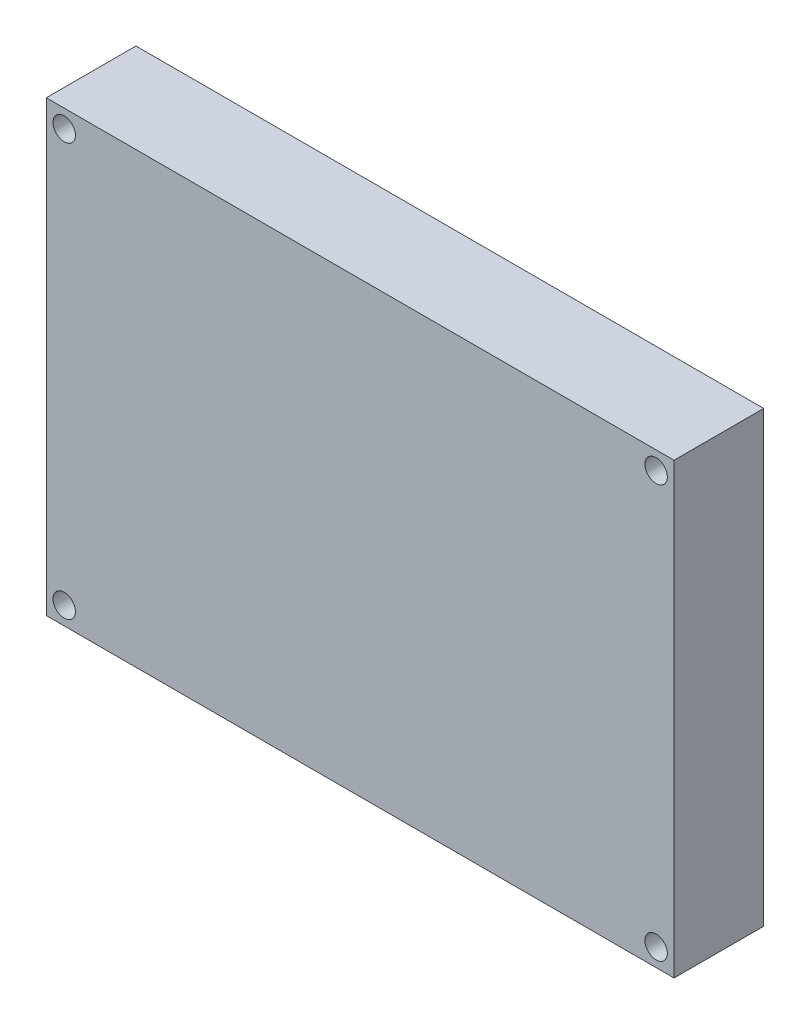
from build123d import *

# Parameters (mm, degrees)
SCHIZZO1_W                   = 70
SCHIZZO1_H                   = 50
ESTRUSIONE_ESTRUSIONE1_DEPTH = 10
SCHIZZO2_R                   = 1.25
TAGLIO_ESTRUSIONE1_DEPTH     = 11


with BuildPart() as part:
    # Schizzo1 → Estrusione-Estrusione1 (new body)
    with BuildSketch(Plane.XY):
        Rectangle(SCHIZZO1_W, SCHIZZO1_H)
    extrude(amount=ESTRUSIONE_ESTRUSIONE1_DEPTH)

    # Schizzo2 → Taglio-Estrusione1 (cut, through all)
    with BuildSketch(Plane.XY.offset(10)):
        with Locations((-33, 23)):
            Circle(SCHIZZO2_R)
        with Locations((33, 23)):
            Circle(SCHIZZO2_R)
        with Locations((33, -23)):
            Circle(SCHIZZO2_R)
        with Locations((-33, -23)):
            Circle(SCHIZZO2_R)
    extrude(amount=-TAGLIO_ESTRUSIONE1_DEPTH, mode=Mode.SUBTRACT)


solid = part.part
